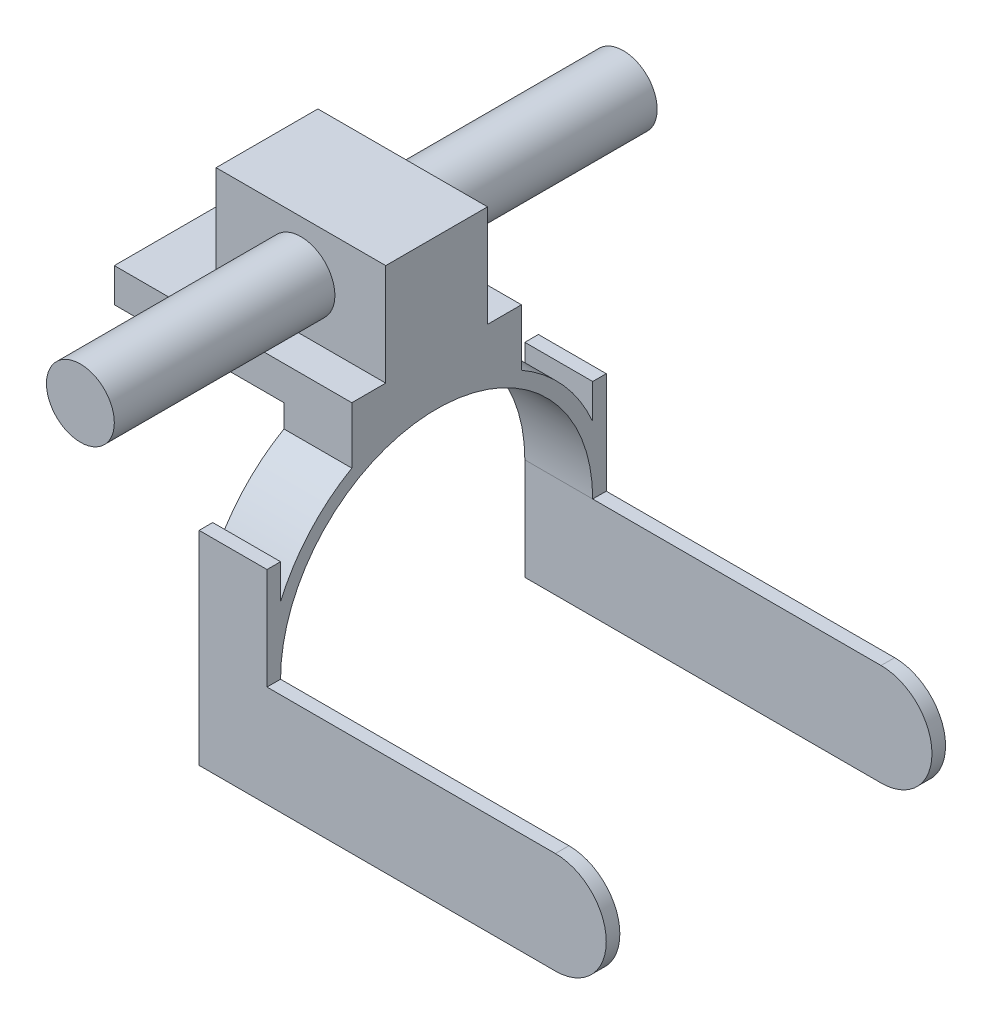
from build123d import *

# Parameters (mm, degrees)
EXTRUDE_1_DEPTH     = 20
SKETCH_2_W          = 4
SKETCH_2_H          = 30
EXTRUDE_2_DEPTH     = 100
CUT_EXTRUDE_1_DEPTH = 100
SKETCH_4_W          = 50
SKETCH_4_H          = 10
EXTRUDE_3_DEPTH     = 50
SKETCH_5_W          = 50
SKETCH_5_H          = 30
EXTRUDE_4_DEPTH     = 30
SKETCH_6_R          = 10
EXTRUDE_5_DEPTH     = 80


with BuildPart() as part:
    # 草图1 → 凸台-拉伸1 (new body)
    with BuildSketch(Plane(origin=(0, 0, 0), x_dir=(0, 0, -1), z_dir=(1, 0, 0))):
        with BuildLine():
            Line((-25, 5), (25, 5))
            Line((25, 5), (25, -5))
            Line((25, -5), (25, -11.698777218))
            ThreePointArc((25, -11.698777218), (37.410642162, -21.801835726), (46, -35.304382227))
            Line((46, -35.304382227), (46, -25.083062159))
            Line((46, -25.083062159), (50, -25.083062159))
            Line((50, -25.083062159), (50, -85.083062159))
            Line((50, -85.083062159), (46, -85.083062159))
            Line((46, -85.083062159), (46, -55.083062159))
            ThreePointArc((46, -55.083062159), (0, -9.083062159), (-46, -55.083062159))
            Line((-46, -55.083062159), (-46, -85.083062159))
            Line((-46, -85.083062159), (-50, -85.083062159))
            Line((-50, -85.083062159), (-50, -25.083062159))
            Line((-50, -25.083062159), (-46, -25.083062159))
            Line((-46, -25.083062159), (-46, -35.304382227))
            ThreePointArc((-46, -35.304382227), (-37.410642162, -21.801835726), (-25, -11.698777218))
            Line((-25, -11.698777218), (-25, -5))
            Line((-25, -5), (-25, 5))
        make_face()
    extrude(amount=EXTRUDE_1_DEPTH)

    # 草图2 → 凸台-拉伸2 (add)
    with BuildSketch(Plane(origin=(20, 0, 0), x_dir=(0, 0, -1), z_dir=(1, 0, 0))):
        with Locations((-48, -70.083062159)):
            Rectangle(SKETCH_2_W, SKETCH_2_H)
        with Locations((48, -70.083062159)):
            Rectangle(SKETCH_2_W, SKETCH_2_H)
    extrude(amount=EXTRUDE_2_DEPTH)

    # 草图3 → 切除-拉伸1 (cut)
    with BuildSketch(Plane.XY.offset(50)):
        with BuildLine():
            Line((105, -55.083062159), (132.360099234, -55.083062159))
            Line((132.360099234, -55.083062159), (132.360099234, -85.083062159))
            Line((132.360099234, -85.083062159), (105, -85.083062159))
            ThreePointArc((105, -85.083062159), (120, -70.083062159), (105, -55.083062159))
        make_face()
    extrude(amount=-CUT_EXTRUDE_1_DEPTH, mode=Mode.SUBTRACT)

    # 草图4 → 凸台-拉伸3 (add)
    with BuildSketch(Plane.ZY):
        Rectangle(SKETCH_4_W, SKETCH_4_H)
    extrude(amount=EXTRUDE_3_DEPTH)

    # 草图5 → 凸台-拉伸4 (add)
    with BuildSketch(Plane(origin=(0, 5, 0), x_dir=(1, 0, 0), z_dir=(0, 1, 0))):
        with Locations((-5, 0)):
            Rectangle(SKETCH_5_W, SKETCH_5_H)
    extrude(amount=EXTRUDE_4_DEPTH)

    # 草图6 → 凸台-拉伸5 (add, symmetric)
    with BuildSketch(Plane.XY):
        with Locations((-5, 19.891808083)):
            Circle(SKETCH_6_R)
    extrude(amount=EXTRUDE_5_DEPTH, both=True)


solid = part.part
